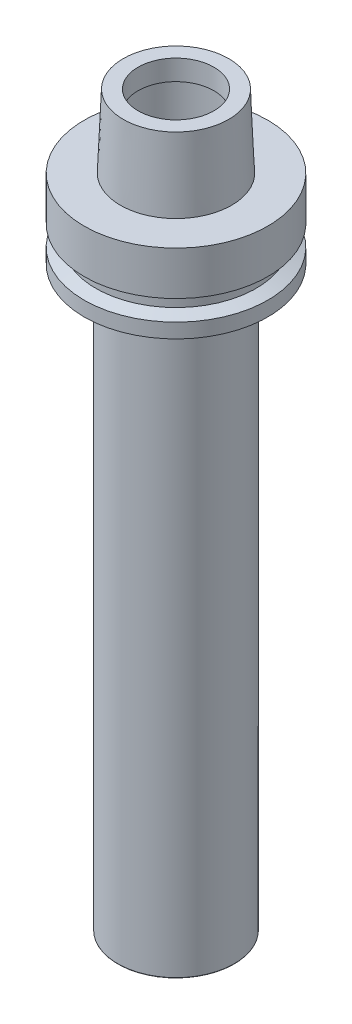
from build123d import *


with BuildPart() as part:
    # Sketch1 → Rivoluzione1 (revolve)
    with BuildSketch(Plane.XY):
        with BuildLine():
            Line((-13, 252.3), (-18.085, 252.3))
            Line((-18.085, 252.3), (-19.1, 227.3))
            Line((-19.1, 227.3), (-31.5, 227.3))
            Line((-31.5, 227.3), (-31.5, 212.3))
            Line((-31.5, 212.3), (-27.5, 210.8))
            Line((-27.5, 210.8), (-27.5, 206.8))
            Line((-27.5, 206.8), (-31.5, 205.3))
            Line((-31.5, 205.3), (-31.5, 200.3))
            Line((-31.5, 200.3), (-20, 200.3))
            Line((-20, 200.3), (-19.75, 200.3))
            ThreePointArc((-19.75, 200.3), (-19.926776695, 200.226776695), (-20, 200.05))
            Line((-20, 200.05), (-20, 2.444337567))
            ThreePointArc((-20, 2.444337567), (-19.966506351, 2.319337567), (-19.875, 2.227831216))
            Line((-19.875, 2.227831216), (-15.669872981, -0.2))
            Line((-15.669872981, -0.2), (-13.5, -0.2))
            Line((-13.5, -0.2), (-13.5, 0))
            Line((-13.5, 0), (-2.5, 0))
            Line((-2.5, 0), (-2.5, 15))
            Line((-2.5, 15), (0, 15))
            Line((0, 15), (0, 218.3))
            Line((0, 218.3), (-13, 218.3))
            Line((-13, 218.3), (-13, 223.3))
            Line((-13, 223.3), (-14, 223.3))
            ThreePointArc((-14, 223.3), (-15.414213562, 223.885786438), (-16, 225.3))
            Line((-16, 225.3), (-16, 243.3))
            ThreePointArc((-16, 243.3), (-15.414213562, 244.714213562), (-14, 245.3))
            Line((-14, 245.3), (-13, 245.3))
            Line((-13, 245.3), (-13, 252.3))
        make_face()
    revolve(axis=Axis((0, 0, 0), (0, 1, 0)))


with BuildPart() as part_1:
    # Corpo-Sposta/copia1: moved
    add(part.part.moved(Location((0, -209, 0))))


solid = part_1.part
